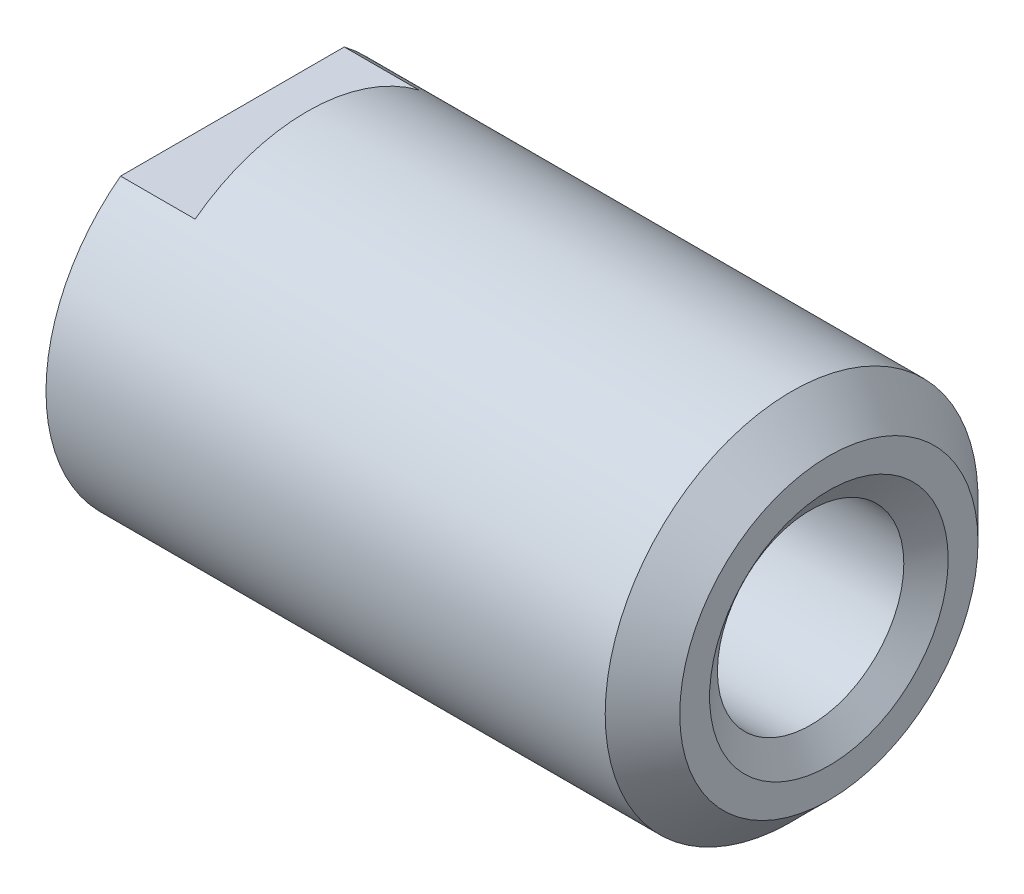
from build123d import *

# Parameters (mm, degrees)
SKETCH_1_W          = 8
SKETCH_1_H          = 1.25
CHAMFER_1_SIZE      = 0.5
CUT_EXTRUDE_1_DEPTH = 1


with BuildPart() as part:
    # Эскиз1 → Повернуть1 (revolve)
    with BuildSketch(Plane.XY):
        with Locations((4, 1.875)):
            Rectangle(SKETCH_1_W, SKETCH_1_H)
    revolve(axis=Axis((0, 0, 0), (1, 0, 0)))

    # Эскиз2 → Отверстие обработанное метчиком M31 (revolve, cut)
    with BuildSketch(Plane(origin=(8, 0, 0), x_dir=(0, 0, -1), z_dir=(0, 1, 0))):
        Polygon((0, 0), (0, 8), (1.6, 8), (1.25, 7.754927362), (1.25, 0.245072638), (1.6, 0), align=None)
    revolve(axis=Axis((14.35, 0, 0), (-1, 0, 0)), mode=Mode.SUBTRACT)

    # Фаска1
    chamfer_1_edges = [part.edges().sort_by_distance(p)[0] for p in [
        (8, -2.5, 0),
    ]]
    chamfer(chamfer_1_edges, length=CHAMFER_1_SIZE)

    # Эскиз4 → Вырез-Вытянуть1 (cut)
    with BuildSketch(Plane.ZY):
        with BuildLine():
            ThreePointArc((1.5, 2), (0, 2.5), (-1.5, 2))
            Line((-1.5, 2), (1.5, 2))
        make_face()
        with BuildLine():
            Line((1.5, -2), (-1.5, -2))
            ThreePointArc((-1.5, -2), (0, -2.5), (1.5, -2))
        make_face()
    extrude(amount=-CUT_EXTRUDE_1_DEPTH, mode=Mode.SUBTRACT)


solid = part.part
